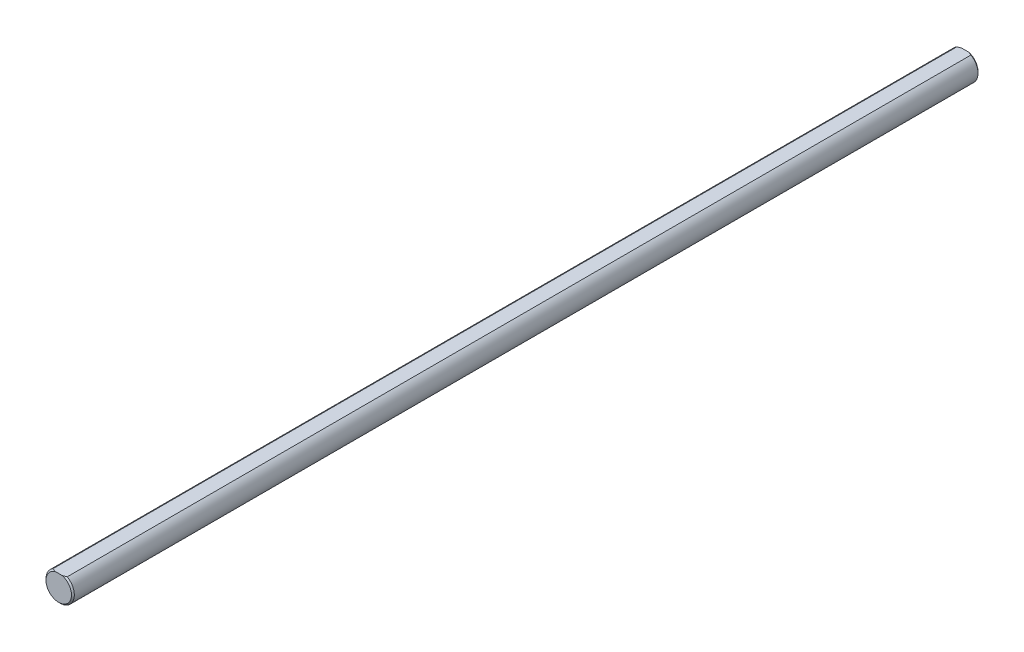
from build123d import *

# Parameters (mm, degrees)
SKETCH3_R                = 4.7625
BOSS_EXTRUDE2_DEPTH      = 152.4
BOSS_EXTRUDE2_DEPTH_BACK = 152.4
CUT_EXTRUDE5_DEPTH       = 153.4
CUT_EXTRUDE5_DEPTH_BACK  = 153.4
CHAMFER1_SIZE            = 0.47625


with BuildPart() as part:
    # Sketch3 → Boss-Extrude2 (new body, two sides)
    with BuildSketch(Plane.XY) as boss_extrude2_sk:
        Circle(SKETCH3_R)
    extrude(amount=BOSS_EXTRUDE2_DEPTH)
    extrude(boss_extrude2_sk.sketch, amount=-BOSS_EXTRUDE2_DEPTH_BACK)

    # Sketch10 → Cut-Extrude5 (cut, two sides)
    with BuildSketch(Plane.XY) as cut_extrude5_sk:
        with BuildLine():
            Line((-2.38125, 4.124445986), (2.38125, 4.124445986))
            ThreePointArc((2.38125, 4.124445986), (0, 4.7625), (-2.38125, 4.124445986))
        make_face()
    extrude(amount=CUT_EXTRUDE5_DEPTH, mode=Mode.SUBTRACT)
    extrude(cut_extrude5_sk.sketch, amount=-CUT_EXTRUDE5_DEPTH_BACK, mode=Mode.SUBTRACT)

    # Chamfer1
    chamfer1_edges = [part.edges().sort_by_distance(p)[0] for p in [
        (0, -4.7625, -152.4),
        (0, -4.7625, 152.4),
    ]]
    chamfer(chamfer1_edges, length=CHAMFER1_SIZE)


solid = part.part
